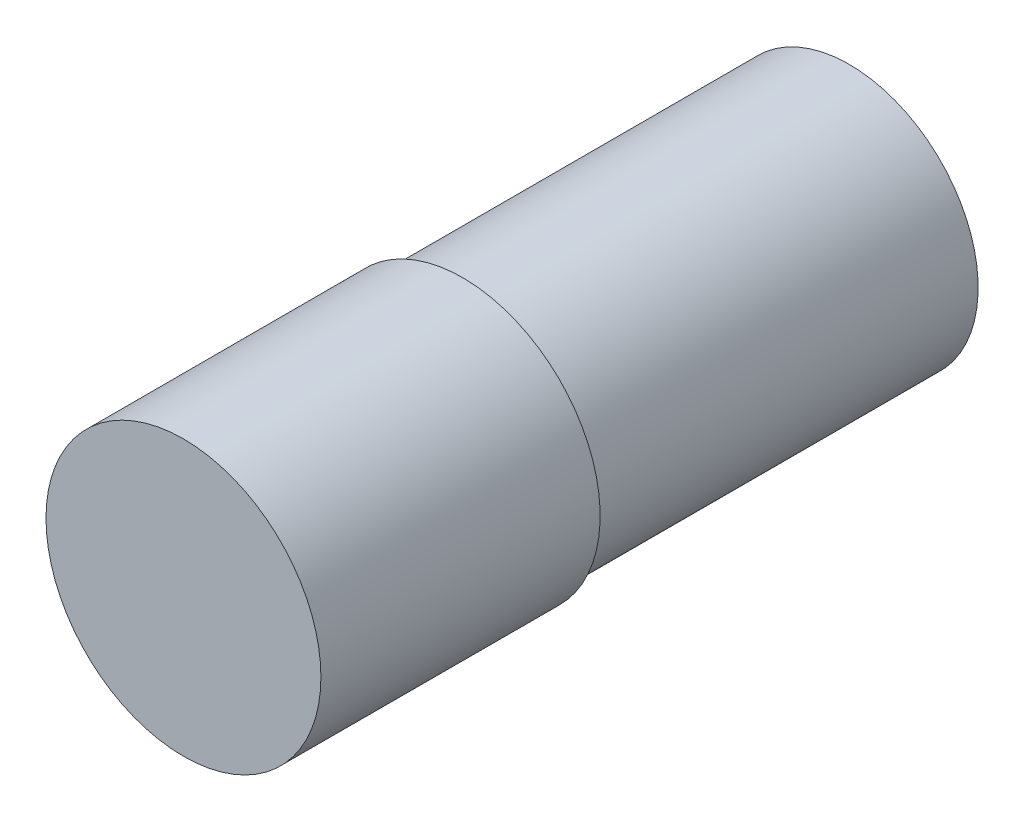
from build123d import *

# Parameters (mm, degrees)
SKETCH1_R           = 3.2
BOSS_EXTRUDE1_DEPTH = 15.5
SKETCH2_R           = 3.2
SKETCH2_R_2         = 3
CUT_EXTRUDE1_DEPTH  = 9


with BuildPart() as part:
    # Sketch1 → Boss-Extrude1 (new body)
    with BuildSketch(Plane.XY):
        Circle(SKETCH1_R)
    extrude(amount=BOSS_EXTRUDE1_DEPTH)

    # Sketch2 → Cut-Extrude1 (cut)
    with BuildSketch(Plane(origin=(0, 0, 0), x_dir=(-1, 0, 0), z_dir=(0, 0, -1))):
        Circle(SKETCH2_R)
        Circle(SKETCH2_R_2, mode=Mode.SUBTRACT)
    extrude(amount=-CUT_EXTRUDE1_DEPTH, mode=Mode.SUBTRACT)


solid = part.part
